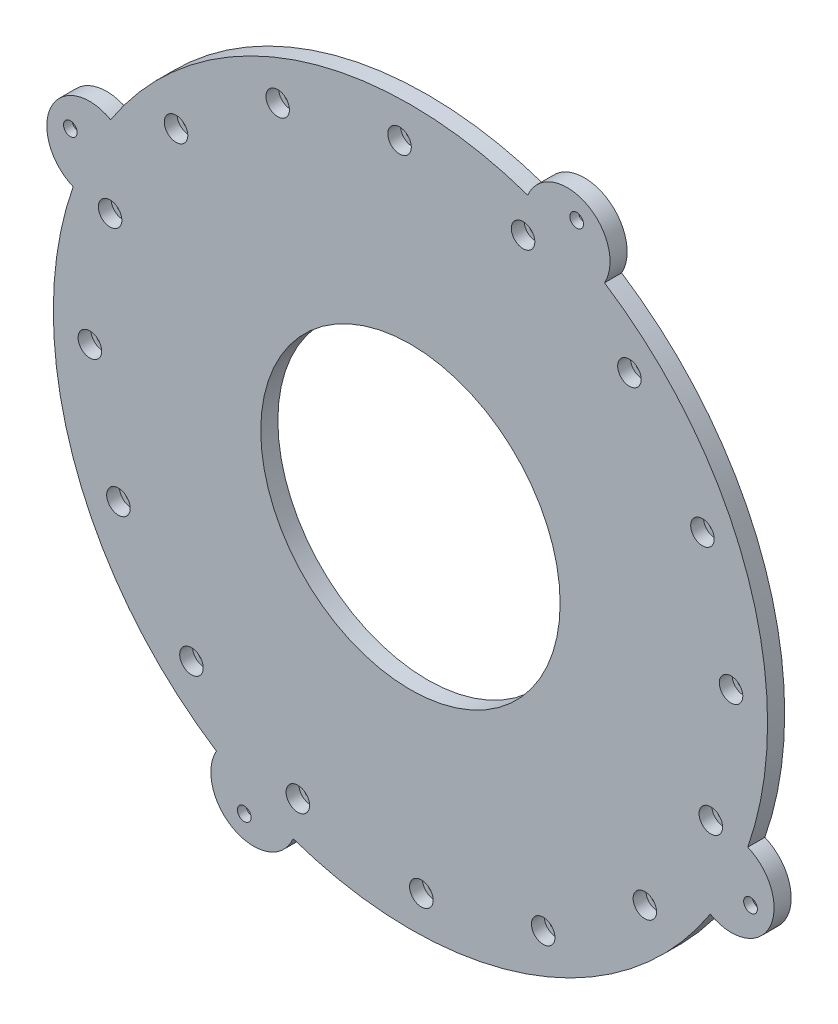
from build123d import *

# Parameters (mm, degrees)
SKETCH1_R           = 83.5
SKETCH1_R_2         = 35
BOSS_EXTRUDE1_DEPTH = 4
CUT_EXTRUDE1_REACH  = 6
SKETCH2_R           = 1.6
SKETCH3_R           = 2.75
CUT_EXTRUDE2_DEPTH  = 3
BOSS_EXTRUDE2_DEPTH = 4
CUT_EXTRUDE3_REACH  = 6
SKETCH5_R           = 1.6
CUT_EXTRUDE4_DEPTH  = 2


with BuildPart() as part:
    # Sketch1 → Boss-Extrude1 (new body)
    with BuildSketch(Plane.XY):
        with Locations((-20.142161583, -37.124408079)):
            Circle(SKETCH1_R)
        with Locations((-20.142161583, -37.124408079)):
            Circle(SKETCH1_R_2, mode=Mode.SUBTRACT)
    extrude(amount=BOSS_EXTRUDE1_DEPTH)

    # Sketch2 → Cut-Extrude1 (cut, up to next)
    with BuildSketch(Plane.XY.offset(4), mode=Mode.PRIVATE) as cut_extrude1_sk1:
        with Locations((-51.182526114, 31.150739448)):
            Circle(SKETCH2_R)
    cut_extrude1_tool1 = extrude(cut_extrude1_sk1.sketch, amount=-CUT_EXTRUDE1_REACH, mode=Mode.PRIVATE) & part.part
    add(cut_extrude1_tool1.solids().sort_by_distance((-51.182526, 31.150739, 4))[0], mode=Mode.SUBTRACT)
    # Sketch2 → Cut-Extrude1 (cut, up to next)
    with BuildSketch(Plane.XY.offset(4), mode=Mode.PRIVATE) as cut_extrude1_sk2:
        with Locations((-22.691951254, 37.83223654)):
            Circle(SKETCH2_R)
    cut_extrude1_tool2 = extrude(cut_extrude1_sk2.sketch, amount=-CUT_EXTRUDE1_REACH, mode=Mode.PRIVATE) & part.part
    add(cut_extrude1_tool2.solids().sort_by_distance((-22.691951, 37.832237, 4))[0], mode=Mode.SUBTRACT)
    # Sketch2 → Cut-Extrude1 (cut, up to next)
    with BuildSketch(Plane.XY.offset(4), mode=Mode.PRIVATE) as cut_extrude1_sk3:
        with Locations((6.186805969, 33.102263974)):
            Circle(SKETCH2_R)
    cut_extrude1_tool3 = extrude(cut_extrude1_sk3.sketch, amount=-CUT_EXTRUDE1_REACH, mode=Mode.PRIVATE) & part.part
    add(cut_extrude1_tool3.solids().sort_by_distance((6.186806, 33.102264, 4))[0], mode=Mode.SUBTRACT)
    # Sketch2 → Cut-Extrude1 (cut, up to next)
    with BuildSketch(Plane.XY.offset(4), mode=Mode.PRIVATE) as cut_extrude1_sk4:
        with Locations((31.057216555, 17.680917193)):
            Circle(SKETCH2_R)
    cut_extrude1_tool4 = extrude(cut_extrude1_sk4.sketch, amount=-CUT_EXTRUDE1_REACH, mode=Mode.PRIVATE) & part.part
    add(cut_extrude1_tool4.solids().sort_by_distance((31.057217, 17.680917, 4))[0], mode=Mode.SUBTRACT)
    # Sketch2 → Cut-Extrude1 (cut, up to next)
    with BuildSketch(Plane.XY.offset(4), mode=Mode.PRIVATE) as cut_extrude1_sk5:
        with Locations((48.132985943, -6.084043548)):
            Circle(SKETCH2_R)
    cut_extrude1_tool5 = extrude(cut_extrude1_sk5.sketch, amount=-CUT_EXTRUDE1_REACH, mode=Mode.PRIVATE) & part.part
    add(cut_extrude1_tool5.solids().sort_by_distance((48.132986, -6.084044, 4))[0], mode=Mode.SUBTRACT)
    # Sketch2 → Cut-Extrude1 (cut, up to next)
    with BuildSketch(Plane.XY.offset(4), mode=Mode.PRIVATE) as cut_extrude1_sk6:
        with Locations((54.814483036, -34.574618408)):
            Circle(SKETCH2_R)
    cut_extrude1_tool6 = extrude(cut_extrude1_sk6.sketch, amount=-CUT_EXTRUDE1_REACH, mode=Mode.PRIVATE) & part.part
    add(cut_extrude1_tool6.solids().sort_by_distance((54.814483, -34.574618, 4))[0], mode=Mode.SUBTRACT)
    # Sketch2 → Cut-Extrude1 (cut, up to next)
    with BuildSketch(Plane.XY.offset(4), mode=Mode.PRIVATE) as cut_extrude1_sk7:
        with Locations((50.084510469, -63.453375632)):
            Circle(SKETCH2_R)
    cut_extrude1_tool7 = extrude(cut_extrude1_sk7.sketch, amount=-CUT_EXTRUDE1_REACH, mode=Mode.PRIVATE) & part.part
    add(cut_extrude1_tool7.solids().sort_by_distance((50.08451, -63.453376, 4))[0], mode=Mode.SUBTRACT)
    # Sketch2 → Cut-Extrude1 (cut, up to next)
    with BuildSketch(Plane.XY.offset(4), mode=Mode.PRIVATE) as cut_extrude1_sk8:
        with Locations((34.663163689, -88.323786218)):
            Circle(SKETCH2_R)
    cut_extrude1_tool8 = extrude(cut_extrude1_sk8.sketch, amount=-CUT_EXTRUDE1_REACH, mode=Mode.PRIVATE) & part.part
    add(cut_extrude1_tool8.solids().sort_by_distance((34.663164, -88.323786, 4))[0], mode=Mode.SUBTRACT)
    # Sketch2 → Cut-Extrude1 (cut, up to next)
    with BuildSketch(Plane.XY.offset(4), mode=Mode.PRIVATE) as cut_extrude1_sk9:
        with Locations((10.898202947, -105.399555606)):
            Circle(SKETCH2_R)
    cut_extrude1_tool9 = extrude(cut_extrude1_sk9.sketch, amount=-CUT_EXTRUDE1_REACH, mode=Mode.PRIVATE) & part.part
    add(cut_extrude1_tool9.solids().sort_by_distance((10.898203, -105.399556, 4))[0], mode=Mode.SUBTRACT)
    # Sketch2 → Cut-Extrude1 (cut, up to next)
    with BuildSketch(Plane.XY.offset(4), mode=Mode.PRIVATE) as cut_extrude1_sk10:
        with Locations((-17.592371912, -112.081052699)):
            Circle(SKETCH2_R)
    cut_extrude1_tool10 = extrude(cut_extrude1_sk10.sketch, amount=-CUT_EXTRUDE1_REACH, mode=Mode.PRIVATE) & part.part
    add(cut_extrude1_tool10.solids().sort_by_distance((-17.592372, -112.081053, 4))[0], mode=Mode.SUBTRACT)
    # Sketch2 → Cut-Extrude1 (cut, up to next)
    with BuildSketch(Plane.XY.offset(4), mode=Mode.PRIVATE) as cut_extrude1_sk11:
        with Locations((-46.471129136, -107.351080132)):
            Circle(SKETCH2_R)
    cut_extrude1_tool11 = extrude(cut_extrude1_sk11.sketch, amount=-CUT_EXTRUDE1_REACH, mode=Mode.PRIVATE) & part.part
    add(cut_extrude1_tool11.solids().sort_by_distance((-46.471129, -107.35108, 4))[0], mode=Mode.SUBTRACT)
    # Sketch2 → Cut-Extrude1 (cut, up to next)
    with BuildSketch(Plane.XY.offset(4), mode=Mode.PRIVATE) as cut_extrude1_sk12:
        with Locations((-71.341539722, -91.929733352)):
            Circle(SKETCH2_R)
    cut_extrude1_tool12 = extrude(cut_extrude1_sk12.sketch, amount=-CUT_EXTRUDE1_REACH, mode=Mode.PRIVATE) & part.part
    add(cut_extrude1_tool12.solids().sort_by_distance((-71.34154, -91.929733, 4))[0], mode=Mode.SUBTRACT)
    # Sketch2 → Cut-Extrude1 (cut, up to next)
    with BuildSketch(Plane.XY.offset(4), mode=Mode.PRIVATE) as cut_extrude1_sk13:
        with Locations((-88.41730911, -68.16477261)):
            Circle(SKETCH2_R)
    cut_extrude1_tool13 = extrude(cut_extrude1_sk13.sketch, amount=-CUT_EXTRUDE1_REACH, mode=Mode.PRIVATE) & part.part
    add(cut_extrude1_tool13.solids().sort_by_distance((-88.417309, -68.164773, 4))[0], mode=Mode.SUBTRACT)
    # Sketch2 → Cut-Extrude1 (cut, up to next)
    with BuildSketch(Plane.XY.offset(4), mode=Mode.PRIVATE) as cut_extrude1_sk14:
        with Locations((-95.098806203, -39.67419775)):
            Circle(SKETCH2_R)
    cut_extrude1_tool14 = extrude(cut_extrude1_sk14.sketch, amount=-CUT_EXTRUDE1_REACH, mode=Mode.PRIVATE) & part.part
    add(cut_extrude1_tool14.solids().sort_by_distance((-95.098806, -39.674198, 4))[0], mode=Mode.SUBTRACT)
    # Sketch2 → Cut-Extrude1 (cut, up to next)
    with BuildSketch(Plane.XY.offset(4), mode=Mode.PRIVATE) as cut_extrude1_sk15:
        with Locations((-90.368833636, -10.795440527)):
            Circle(SKETCH2_R)
    cut_extrude1_tool15 = extrude(cut_extrude1_sk15.sketch, amount=-CUT_EXTRUDE1_REACH, mode=Mode.PRIVATE) & part.part
    add(cut_extrude1_tool15.solids().sort_by_distance((-90.368834, -10.795441, 4))[0], mode=Mode.SUBTRACT)
    # Sketch2 → Cut-Extrude1 (cut, up to next)
    with BuildSketch(Plane.XY.offset(4), mode=Mode.PRIVATE) as cut_extrude1_sk16:
        with Locations((-74.947486856, 14.074970059)):
            Circle(SKETCH2_R)
    cut_extrude1_tool16 = extrude(cut_extrude1_sk16.sketch, amount=-CUT_EXTRUDE1_REACH, mode=Mode.PRIVATE) & part.part
    add(cut_extrude1_tool16.solids().sort_by_distance((-74.947487, 14.07497, 4))[0], mode=Mode.SUBTRACT)

    # Sketch3 → Cut-Extrude2 (cut)
    with BuildSketch(Plane.XY.offset(4)):
        with Locations((-74.947486856, 14.074970059)):
            Circle(SKETCH3_R)
        with Locations((-51.182526114, 31.150739448)):
            Circle(SKETCH3_R)
        with Locations((-22.691951254, 37.83223654)):
            Circle(SKETCH3_R)
        with Locations((6.186805969, 33.102263974)):
            Circle(SKETCH3_R)
        with Locations((31.057216555, 17.680917193)):
            Circle(SKETCH3_R)
        with Locations((48.132985943, -6.084043548)):
            Circle(SKETCH3_R)
        with Locations((54.814483036, -34.574618408)):
            Circle(SKETCH3_R)
        with Locations((50.084510469, -63.453375632)):
            Circle(SKETCH3_R)
        with Locations((34.663163689, -88.323786218)):
            Circle(SKETCH3_R)
        with Locations((10.898202947, -105.399555606)):
            Circle(SKETCH3_R)
        with Locations((-17.592371912, -112.081052699)):
            Circle(SKETCH3_R)
        with Locations((-46.471129136, -107.351080132)):
            Circle(SKETCH3_R)
        with Locations((-71.341539722, -91.929733352)):
            Circle(SKETCH3_R)
        with Locations((-88.41730911, -68.16477261)):
            Circle(SKETCH3_R)
        with Locations((-95.098806203, -39.67419775)):
            Circle(SKETCH3_R)
        with Locations((-90.368833636, -10.795440527)):
            Circle(SKETCH3_R)
    extrude(amount=-CUT_EXTRUDE2_DEPTH, mode=Mode.SUBTRACT)

    # Sketch4 → Boss-Extrude2 (add)
    with BuildSketch(Plane.XY.offset(4)):
        with BuildLine():
            ThreePointArc((7.293076451, 41.739764483), (20.915373779, 46.878739421), (25.229420752, 32.973163323))
            ThreePointArc((25.229420752, 32.973163323), (16.524193527, 37.894445571), (7.293076451, 41.739764483))
        make_face()
        with BuildLine():
            ThreePointArc((58.722010979, -64.559646114), (54.876692066, -73.790763189), (49.955409818, -82.495990414))
            ThreePointArc((49.955409818, -82.495990414), (63.860985917, -78.181943442), (58.722010979, -64.559646114))
        make_face()
        with BuildLine():
            ThreePointArc((-47.577399618, -115.988580642), (-56.808516694, -112.143261729), (-65.513743918, -107.221979481))
            ThreePointArc((-65.513743918, -107.221979481), (-61.199696946, -121.127555579), (-47.577399618, -115.988580642))
        make_face()
        with BuildLine():
            ThreePointArc((-99.006334146, -9.689170044), (-95.161015233, -0.458052969), (-90.239732985, 8.247174256))
            ThreePointArc((-90.239732985, 8.247174256), (-104.145309084, 3.933127284), (-99.006334146, -9.689170044))
        make_face()
    extrude(amount=-BOSS_EXTRUDE2_DEPTH)

    # Sketch5 → Cut-Extrude3 (cut, up to next)
    with BuildSketch(Plane(origin=(0, 0, 0), x_dir=(-1, 0, 0), z_dir=(0, 0, -1)), mode=Mode.PRIVATE) as cut_extrude3_sk1:
        with Locations((59.00410682, -116.635408654)):
            Circle(SKETCH5_R)
    cut_extrude3_tool1 = extrude(cut_extrude3_sk1.sketch, amount=-CUT_EXTRUDE3_REACH, mode=Mode.PRIVATE) & part.part
    add(cut_extrude3_tool1.solids().sort_by_distance((-59.004107, -116.635409, 0))[0], mode=Mode.SUBTRACT)
    # Sketch5 → Cut-Extrude3 (cut, up to next)
    with BuildSketch(Plane(origin=(0, 0, 0), x_dir=(-1, 0, 0), z_dir=(0, 0, -1)), mode=Mode.PRIVATE) as cut_extrude3_sk2:
        with Locations((-59.368838992, -75.986353316)):
            Circle(SKETCH5_R)
    cut_extrude3_tool2 = extrude(cut_extrude3_sk2.sketch, amount=-CUT_EXTRUDE3_REACH, mode=Mode.PRIVATE) & part.part
    add(cut_extrude3_tool2.solids().sort_by_distance((59.368839, -75.986353, 0))[0], mode=Mode.SUBTRACT)
    # Sketch5 → Cut-Extrude3 (cut, up to next)
    with BuildSketch(Plane(origin=(0, 0, 0), x_dir=(-1, 0, 0), z_dir=(0, 0, -1)), mode=Mode.PRIVATE) as cut_extrude3_sk3:
        with Locations((-18.719783653, 42.386592496)):
            Circle(SKETCH5_R)
    cut_extrude3_tool3 = extrude(cut_extrude3_sk3.sketch, amount=-CUT_EXTRUDE3_REACH, mode=Mode.PRIVATE) & part.part
    add(cut_extrude3_tool3.solids().sort_by_distance((18.719784, 42.386592, 0))[0], mode=Mode.SUBTRACT)
    # Sketch5 → Cut-Extrude3 (cut, up to next)
    with BuildSketch(Plane(origin=(0, 0, 0), x_dir=(-1, 0, 0), z_dir=(0, 0, -1)), mode=Mode.PRIVATE) as cut_extrude3_sk4:
        with Locations((99.653162158, 1.737537157)):
            Circle(SKETCH5_R)
    cut_extrude3_tool4 = extrude(cut_extrude3_sk4.sketch, amount=-CUT_EXTRUDE3_REACH, mode=Mode.PRIVATE) & part.part
    add(cut_extrude3_tool4.solids().sort_by_distance((-99.653162, 1.737537, 0))[0], mode=Mode.SUBTRACT)

    # Sketch6 → Cut-Extrude4 (cut)
    with BuildSketch(Plane(origin=(0, 0, 0), x_dir=(-1, 0, 0), z_dir=(0, 0, -1))):
        Polygon((-56.101046154, -76.375621821), (-57.397826158, -73.350995957), (-60.665618996, -72.961727451), (-62.636631829, -75.59708481), (-61.339851825, -78.621710675), (-58.072058987, -79.01097918), align=None)
        Polygon((55.979480955, -117.932188658), (58.614838314, -119.903201492), (61.639464179, -118.606421488), (62.028732685, -115.33862865), (59.393375325, -113.367615816), (56.368749461, -114.664395821), align=None)
        Polygon((-19.109052159, 39.118799658), (-16.084426294, 40.415579662), (-15.695157789, 43.6833725), (-18.330515148, 45.654385334), (-21.355141012, 44.357605329), (-21.744409518, 41.089812492), align=None)
        Polygon((96.385369321, 2.126805663), (97.682149325, -0.897820202), (100.949942163, -1.287088707), (102.920954996, 1.348268652), (101.624174992, 4.372894516), (98.356382154, 4.762163022), align=None)
    extrude(amount=-CUT_EXTRUDE4_DEPTH, mode=Mode.SUBTRACT)


solid = part.part
